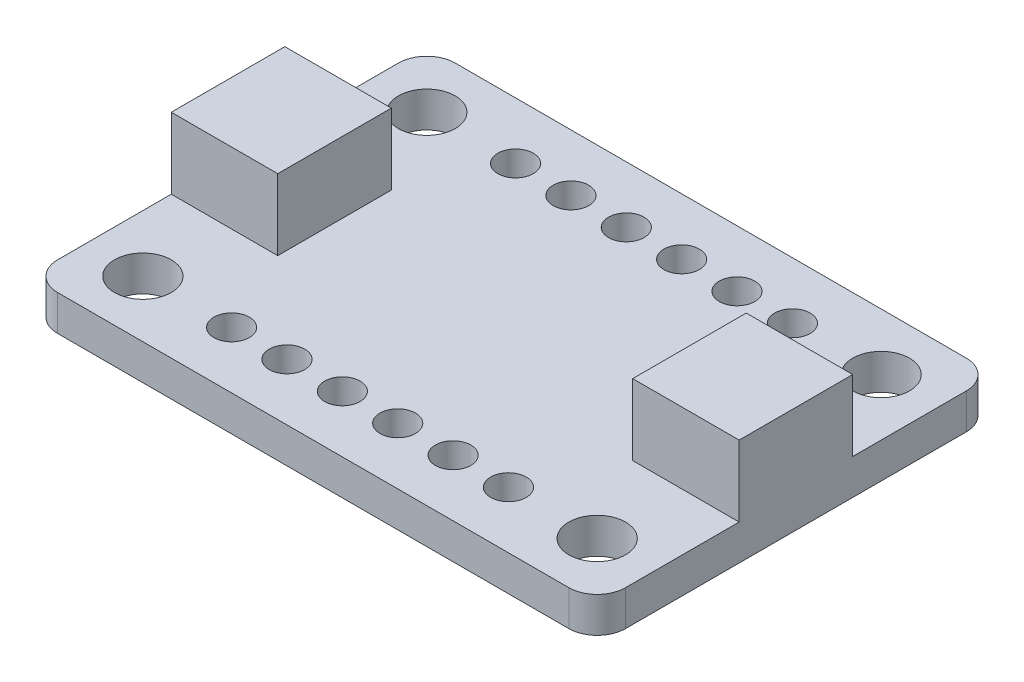
from build123d import *

# Parameters (mm, degrees)
SKETCH1_R           = 1.27
BOSS_EXTRUDE1_DEPTH = 1.5875
SKETCH2_R           = 0.79375
CUT_EXTRUDE1_DEPTH  = 1.5875
SKETCH4_W           = 4.7625
SKETCH4_H           = 5.08
BOSS_EXTRUDE2_DEPTH = 3.175


with BuildPart() as part:
    # Sketch1 → Boss-Extrude1 (new body)
    with BuildSketch(Plane(origin=(0, 0, 0), x_dir=(1, 0, 0), z_dir=(0, 1, 0))):
        with BuildLine():
            Line((1.27, 0), (24.13, 0))
            ThreePointArc((24.13, 0), (25.028025612, 0.371974388), (25.4, 1.27))
            Line((25.4, 1.27), (25.4, 16.51))
            ThreePointArc((25.4, 16.51), (25.028025612, 17.408025612), (24.13, 17.78))
            Line((24.13, 17.78), (1.27, 17.78))
            ThreePointArc((1.27, 17.78), (0.371974388, 17.408025612), (0, 16.51))
            Line((0, 16.51), (0, 1.27))
            ThreePointArc((0, 1.27), (0.371974388, 0.371974388), (1.27, 0))
        make_face()
        with Locations((2.54, 15.24)):
            Circle(SKETCH1_R, mode=Mode.SUBTRACT)
        with Locations((22.86, 15.24)):
            Circle(SKETCH1_R, mode=Mode.SUBTRACT)
        with Locations((22.86, 2.54)):
            Circle(SKETCH1_R, mode=Mode.SUBTRACT)
        with Locations((2.54, 2.54)):
            Circle(SKETCH1_R, mode=Mode.SUBTRACT)
    extrude(amount=BOSS_EXTRUDE1_DEPTH)

    # Sketch2 → Cut-Extrude1 (cut)
    with BuildSketch(Plane(origin=(0, 1.5875, 0), x_dir=(1, 0, 0), z_dir=(0, 1, 0))):
        with Locations((6.50875, 15.24)):
            Circle(SKETCH2_R)
        with Locations((8.98525, 15.24)):
            Circle(SKETCH2_R)
        with Locations((11.46175, 15.24)):
            Circle(SKETCH2_R)
        with Locations((13.93825, 15.24)):
            Circle(SKETCH2_R)
        with Locations((16.41475, 15.24)):
            Circle(SKETCH2_R)
        with Locations((18.89125, 15.24)):
            Circle(SKETCH2_R)
        with Locations((6.50875, 2.54)):
            Circle(SKETCH2_R)
        with Locations((8.98525, 2.54)):
            Circle(SKETCH2_R)
        with Locations((11.46175, 2.54)):
            Circle(SKETCH2_R)
        with Locations((13.93825, 2.54)):
            Circle(SKETCH2_R)
        with Locations((16.41475, 2.54)):
            Circle(SKETCH2_R)
        with Locations((18.89125, 2.54)):
            Circle(SKETCH2_R)
    extrude(amount=-CUT_EXTRUDE1_DEPTH, mode=Mode.SUBTRACT)

    # Sketch4 → Boss-Extrude2 (add)
    with BuildSketch(Plane(origin=(0, 1.5875, 0), x_dir=(1, 0, 0), z_dir=(0, 1, 0))):
        with Locations((23.01875, 8.89)):
            Rectangle(SKETCH4_W, SKETCH4_H)
        with Locations((2.38125, 8.89)):
            Rectangle(SKETCH4_W, SKETCH4_H)
    extrude(amount=BOSS_EXTRUDE2_DEPTH)


solid = part.part
